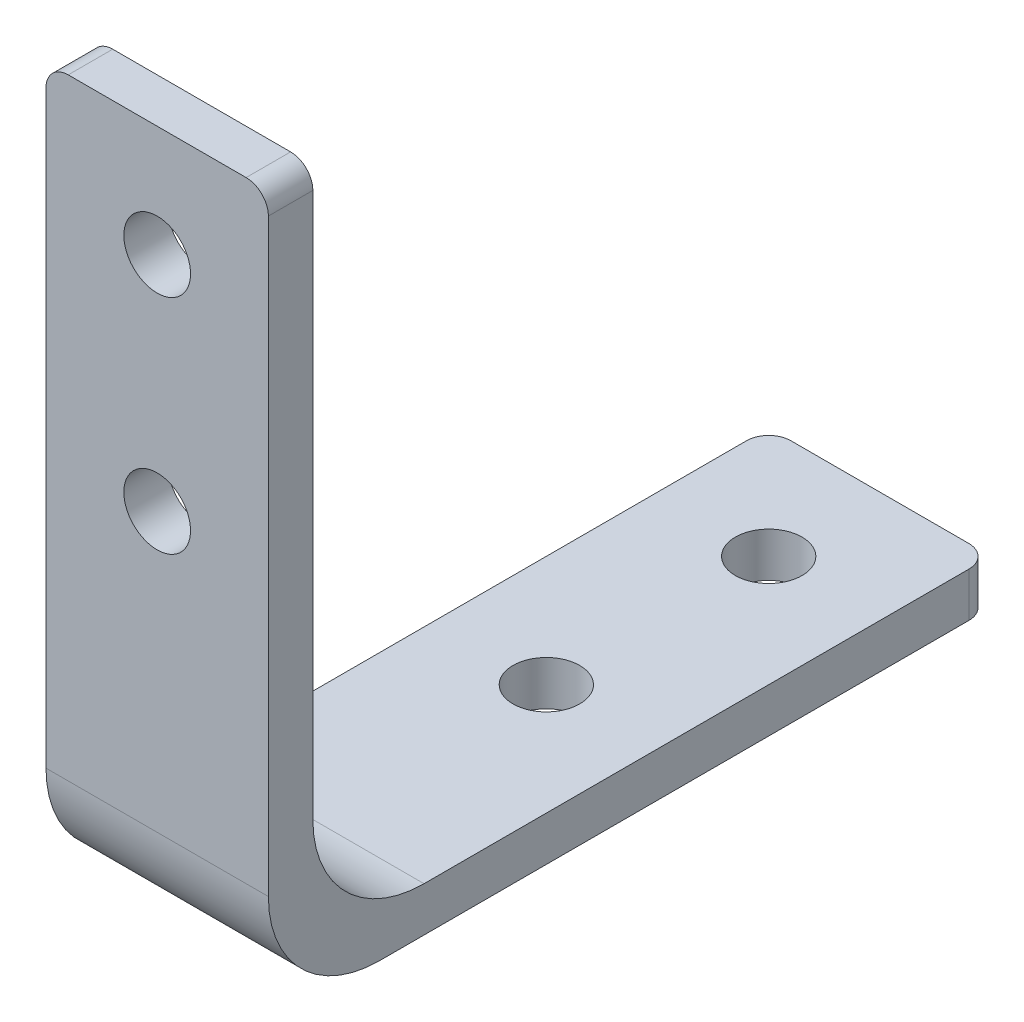
from build123d import *

# Parameters (mm, degrees)
EXTRUDE_1_DEPTH      = 5
EXTRUDE_1_DEPTH_BACK = 5
SKETCH_2_R           = 1.5
CUT_EXTRUDE_1_DEPTH  = 45.849749163
SKETCH_3_R           = 1.5
CUT_EXTRUDE_2_DEPTH  = 45.849749163
FILLET_1_R           = 1
FILLET_2_R           = 5


with BuildPart() as part:
    # Эскиз1 → Бобышка-Вытянуть1 (new, two sides: drawn at the far end of the back side and taken through both)
    with BuildSketch(Plane(origin=(0, 0, 0), x_dir=(0, 0, -1), z_dir=(1, 0, 0)).offset(-EXTRUDE_1_DEPTH_BACK)):
        Polygon((0, 32.5), (0, 0), (32.5, 0), (32.5, 2), (2, 2), (2, 32.5), align=None)
    extrude(amount=EXTRUDE_1_DEPTH + EXTRUDE_1_DEPTH_BACK)

    # Эскиз2 → Вырез-Вытянуть1 (cut, through all)
    with BuildSketch(Plane(origin=(0, 2, 0), x_dir=(1, 0, 0), z_dir=(0, 1, 0))):
        with Locations((0, 27.5)):
            Circle(SKETCH_2_R)
        with Locations((0, 17.5)):
            Circle(SKETCH_2_R)
    extrude(amount=-CUT_EXTRUDE_1_DEPTH, mode=Mode.SUBTRACT)

    # Эскиз3 → Вырез-Вытянуть2 (cut, through all)
    with BuildSketch(Plane(origin=(0, 0, -2), x_dir=(-1, 0, 0), z_dir=(0, 0, -1))):
        with Locations((0, 27.5)):
            Circle(SKETCH_3_R)
        with Locations((0, 17.5)):
            Circle(SKETCH_3_R)
    extrude(amount=-CUT_EXTRUDE_2_DEPTH, mode=Mode.SUBTRACT)

    # Скругление1
    fillet_1_edges = [part.edges().sort_by_distance(p)[0] for p in [
        (-5, 1, -32.5),
        (5, 1, -32.5),
        (5, 32.5, -1),
        (-5, 32.5, -1),
    ]]
    fillet(fillet_1_edges, radius=FILLET_1_R)

    # Скругление2
    fillet_2_edges = [part.edges().sort_by_distance(p)[0] for p in [
        (0, 0, 0),
        (0, 2, -2),
    ]]
    fillet(fillet_2_edges, radius=FILLET_2_R)


solid = part.part
